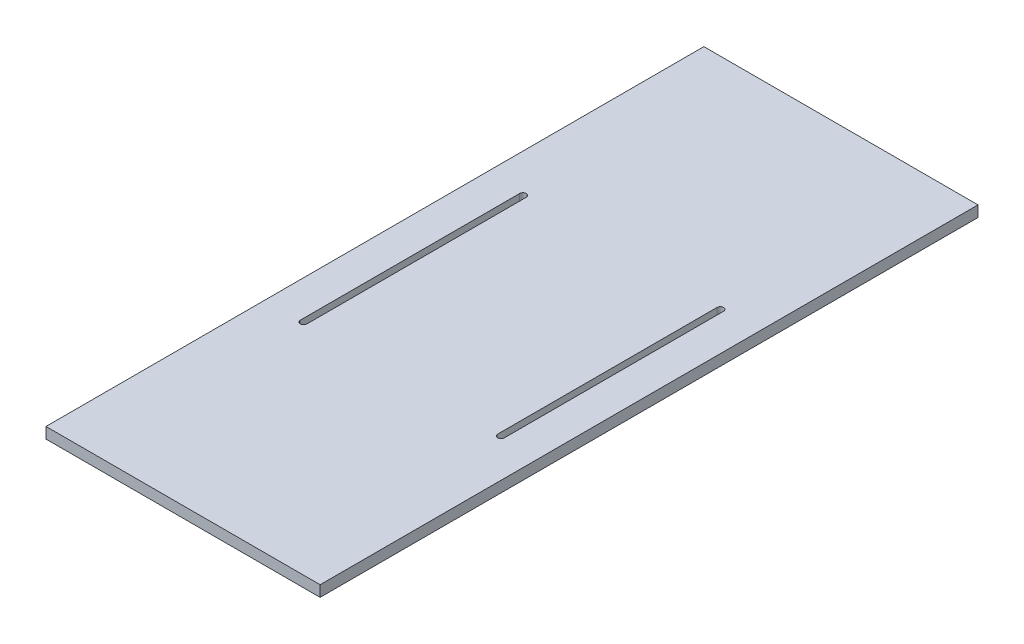
from build123d import *

# Parameters (mm, degrees)
SKETCH_1_W          = 250
SKETCH_1_H          = 600
EXTRUDE_1_DEPTH     = 5
CUT_EXTRUDE_1_DEPTH = 11


with BuildPart() as part:
    # 草图1 → 凸台-拉伸1 (new body, symmetric)
    with BuildSketch(Plane(origin=(0, 0, 0), x_dir=(1, 0, 0), z_dir=(0, 1, 0))):
        Rectangle(SKETCH_1_W, SKETCH_1_H)
    extrude(amount=EXTRUDE_1_DEPTH, both=True)

    # 草图2 → 切除-拉伸1 (cut, through all)
    with BuildSketch(Plane(origin=(0, 5, 0), x_dir=(1, 0, 0), z_dir=(0, 1, 0))):
        with BuildLine():
            Line((-87, 100), (-87, -100))
            ThreePointArc((-87, -100), (-90, -103), (-93, -100))
            Line((-93, -100), (-93, 100))
            ThreePointArc((-93, 100), (-90, 103), (-87, 100))
        make_face()
        with BuildLine():
            Line((87, 100), (87, -100))
            ThreePointArc((87, -100), (90, -103), (93, -100))
            Line((93, -100), (93, 100))
            ThreePointArc((93, 100), (90, 103), (87, 100))
        make_face()
    extrude(amount=-CUT_EXTRUDE_1_DEPTH, mode=Mode.SUBTRACT)


solid = part.part
